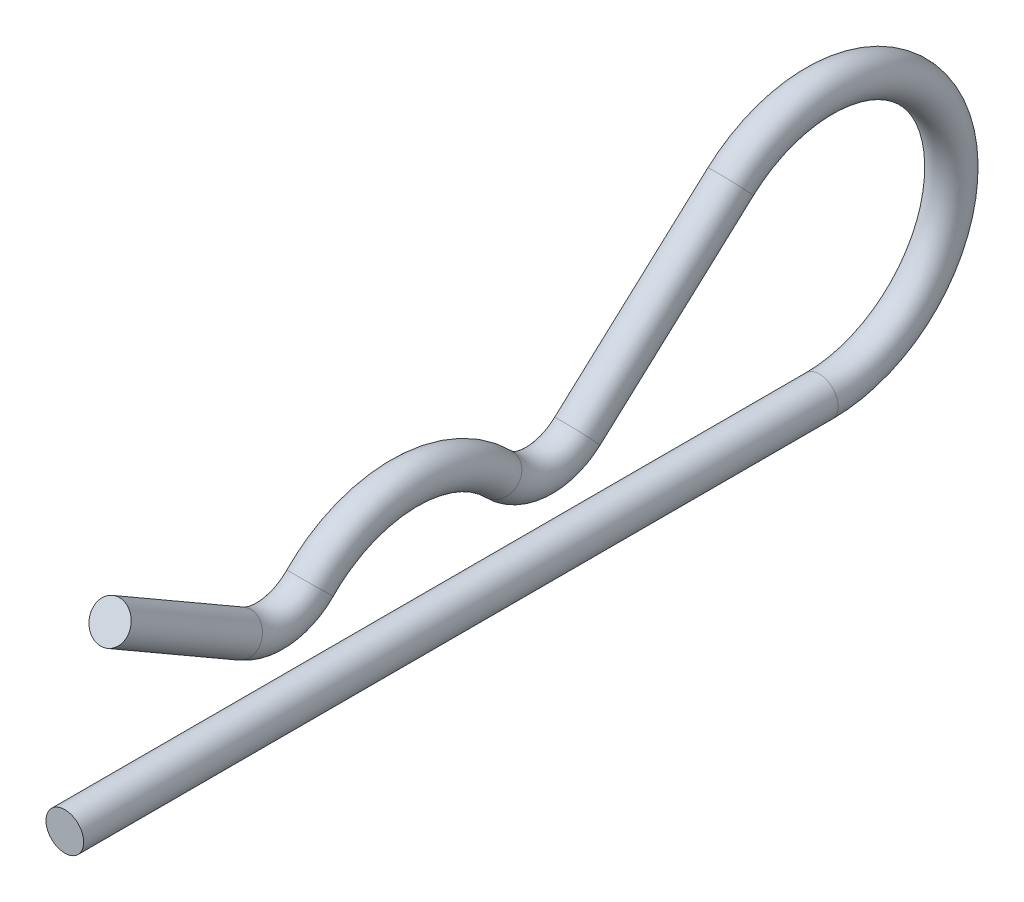
from build123d import *

# Parameters (mm, degrees)
SKETCH2_R = 1.5


with BuildPart() as part:
    # Sweep1: sweep along a path in Sketch3
    with BuildLine(Plane(origin=(0, 0, 0), x_dir=(0, 0, -1), z_dir=(1, 0, 0))) as sweep1_path:
        Line((-32.4, 12.629185438), (-21.962142643, 6.602885683))
        ThreePointArc((-21.962142643, 6.602885683), (-19.102473217, 6.041490923), (-16.49849985, 7.35))
        ThreePointArc((-16.49849985, 7.35), (-9, 10.5), (-1.50150015, 7.35))
        ThreePointArc((-1.50150015, 7.35), (1.583628924, 6.001835461), (4.74069756, 7.171658805))
        Line((4.74069756, 7.171658805), (16.933371859, 18.266129455))
        ThreePointArc((16.933371859, 18.266129455), (33.792710536, 14.288511628), (24, 0))
        Line((24, 0), (-36, 0))
    # Sketch2 → Sweep1 (sweep)
    with BuildSketch(Plane.XY.offset(36)):
        Circle(SKETCH2_R)
    sweep(path=sweep1_path.line)


solid = part.part
